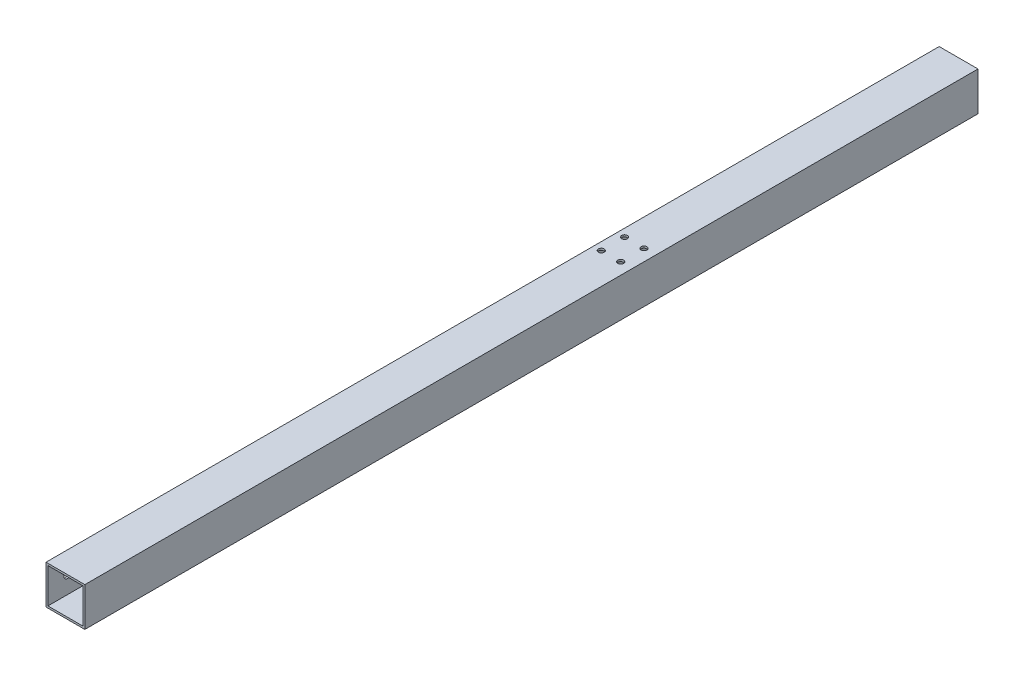
from build123d import *

# Parameters (mm, degrees)
SKETCH_1_W          = 20
SKETCH_1_H          = 20
SKETCH_1_W_2        = 18
SKETCH_1_H_2        = 18
EXTRUDE_1_DEPTH     = 460
SKETCH_2_R          = 1.8
CUT_EXTRUDE_1_DEPTH = 3
SKETCH_3_R          = 1.8
CUT_EXTRUDE_2_DEPTH = 3
SKETCH_5_R          = 1.8
CUT_EXTRUDE_3_DEPTH = 3
SKETCH_6_R          = 1.8
CUT_EXTRUDE_4_DEPTH = 10
SKETCH_7_R          = 1.5
CUT_EXTRUDE_5_DEPTH = 20


with BuildPart() as part:
    # 草图1 → 凸台-拉伸1 (new body)
    with BuildSketch(Plane.XY):
        Rectangle(SKETCH_1_W, SKETCH_1_H)
        Rectangle(SKETCH_1_W_2, SKETCH_1_H_2, mode=Mode.SUBTRACT)
    extrude(amount=EXTRUDE_1_DEPTH)

    # 草图2 → 切除-拉伸1 (cut)
    with BuildSketch(Plane.ZY.offset(10)):
        with Locations((10, 0)):
            Circle(SKETCH_2_R)
    extrude(amount=-CUT_EXTRUDE_1_DEPTH, mode=Mode.SUBTRACT)

    # 草图3 → 切除-拉伸2 (cut)
    with BuildSketch(Plane.ZY.offset(10)):
        with Locations((198, 0)):
            Circle(SKETCH_3_R)
    extrude(amount=-CUT_EXTRUDE_2_DEPTH, mode=Mode.SUBTRACT)

    # 草图5 → 切除-拉伸3 (cut)
    with BuildSketch(Plane.ZY.offset(10)):
        with Locations((450, 0)):
            Circle(SKETCH_5_R)
    extrude(amount=-CUT_EXTRUDE_3_DEPTH, mode=Mode.SUBTRACT)

    # 草图6 → 切除-拉伸4 (cut)
    with BuildSketch(Plane.ZY.offset(10)):
        with Locations((262, 0)):
            Circle(SKETCH_6_R)
    extrude(amount=-CUT_EXTRUDE_4_DEPTH, mode=Mode.SUBTRACT)

    # 草图7 → 切除-拉伸5 (cut)
    with BuildSketch(Plane(origin=(0, 10, 0), x_dir=(1, 0, 0), z_dir=(0, 1, 0))):
        with Locations((4, -166)):
            Circle(SKETCH_7_R)
        with Locations((-6, -166)):
            Circle(SKETCH_7_R)
        with Locations((4, -178)):
            Circle(SKETCH_7_R)
        with Locations((-6, -178)):
            Circle(SKETCH_7_R)
    extrude(amount=-CUT_EXTRUDE_5_DEPTH, mode=Mode.SUBTRACT)


solid = part.part
